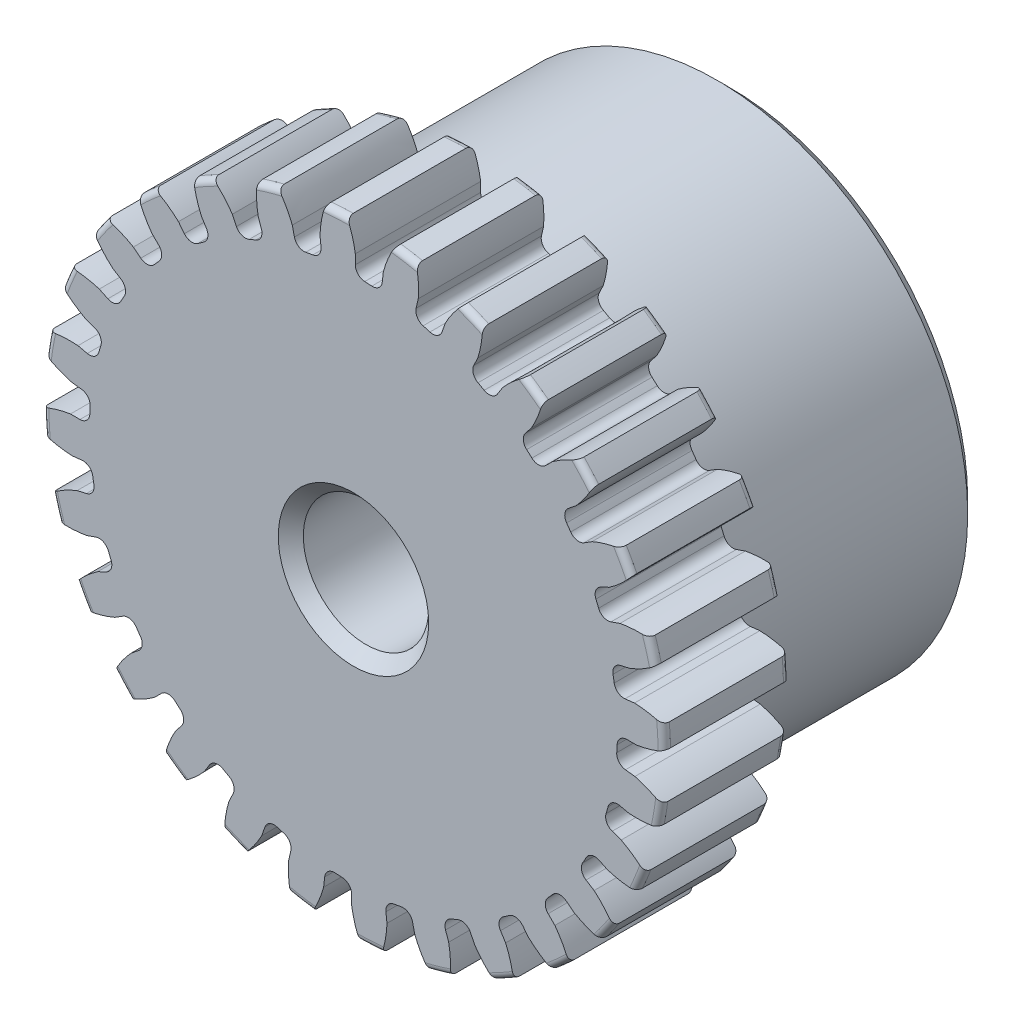
from build123d import *

# Parameters (mm, degrees)
SKETCH1_R                = 7.874
BOSS_EXTRUDE1_DEPTH      = 3.175
SKETCH2_W                = 6.35
SKETCH2_H                = 6.35
FILLET2_R                = 0.15748
CUT_EXTRUDE1_DEPTH       = 10.525
FILLET1_R                = 0.249222006
CIRPATTERN1_COUNT        = 28
FILLET1_OF_CIRPATTERN1_R = 0.249222006
SKETCH5_R                = 1.5875
CUT_EXTRUDE2_DEPTH       = 10.525
CHAMFER1_SIZE            = 0.3175


with BuildPart() as part:
    # Sketch1 → Boss-Extrude1 (new body)
    with BuildSketch(Plane.XY):
        Circle(SKETCH1_R)
    extrude(amount=-BOSS_EXTRUDE1_DEPTH)

    # Sketch2 → Revolve1 (revolve)
    with BuildSketch(Plane(origin=(0, 0, 0), x_dir=(0, 0, -1), z_dir=(1, 0, 0))):
        with Locations((6.35, 3.175)):
            Rectangle(SKETCH2_W, SKETCH2_H)
    revolve(axis=Axis((0, 0, -3.175), (0, 0, -1)))

    # Fillet2
    fillet2_edges = [part.edges().sort_by_distance(p)[0] for p in [
        (-7.874, 0, 0),
        (-7.874, 0, -3.175),
        (0, -6.35, -3.175),
    ]]
    fillet(fillet2_edges, radius=FILLET2_R)

    # Sketch4 → Cut-Extrude1 (cut, through all)
    with BuildSketch(Plane.XY):
        with BuildLine():
            Line((0.046407635, 7.16811172), (0.046407635, 6.68389425))
            ThreePointArc((0.046407635, 6.68389425), (0.374778849, 6.673540052), (0.702244628, 6.647063148))
            Line((0.702244628, 6.647063148), (0.75645991, 7.128235946))
            add(Edge.make_bspline(
                [(1.714771634, 8.558246366), (0.980352344, 7.965902347), (0.75645991, 7.128235946)],
                knots=[0, 0, 0, 1, 1, 1], degree=2))
            ThreePointArc((1.714771634, 8.558246366), (0.489403403, 8.714614559), (-0.745767657, 8.696427612))
            add(Edge.make_bspline(
                [(-0.745767657, 8.696427612), (-0.082287906, 8.025579083), (0.046407635, 7.16811172)],
                knots=[0, 0, 0, 1, 1, 1], degree=2))
        make_face()
    cut_extrude1 = extrude(amount=-CUT_EXTRUDE1_DEPTH, mode=Mode.SUBTRACT)

    # Fillet1
    fillet1_edges = [part.edges().sort_by_distance(p)[0] for p in [
        (0.702244628, 6.647063148, -1.5875),
        (0.046407635, 6.68389425, -1.5875),
    ]]
    fillet(fillet1_edges, radius=FILLET1_R)

    # CirPattern1: Cut-Extrude1 ×28 about axis
    cirpattern1_axis = Axis((0, 0, -3.175), (0, 0, 1))
    for i in range(1, CIRPATTERN1_COUNT):
        add(cut_extrude1.rotate(cirpattern1_axis, i * 360 / CIRPATTERN1_COUNT), mode=Mode.SUBTRACT)

    # Fillet1 of CirPattern1
    fillet1_of_cirpattern1_edges = [part.edges().sort_by_distance(p)[0] for p in [
        (-0.794472811, 6.636671528, -1.5875),
        (-1.442062292, 6.526641737, -1.5875),
        (-2.251352065, 6.293489485, -1.5875),
        (-2.858221195, 6.042116154, -1.5875),
        (-3.595339127, 5.6347256, -1.5875),
        (-4.131056951, 5.254613638, -1.5875),
        (-4.759040871, 4.693413044, -1.5875),
        (-5.196744263, 4.203622852, -1.5875),
        (-5.684104435, 3.516753161, -1.5875),
        (-6.001845118, 2.941844864, -1.5875),
        (-6.324143267, 2.163748589, -1.5875),
        (-6.505988396, 1.53255049, -1.5875),
        (-6.647063148, 0.702244628, -1.5875),
        (-6.68389425, 0.046407635, -1.5875),
        (-6.636671528, -0.794472811, -1.5875),
        (-6.526641737, -1.442062292, -1.5875),
        (-6.293489485, -2.251352065, -1.5875),
        (-6.042116154, -2.858221195, -1.5875),
        (-5.6347256, -3.595339127, -1.5875),
        (-5.254613638, -4.131056951, -1.5875),
        (-4.693413044, -4.759040871, -1.5875),
        (-4.203622852, -5.196744263, -1.5875),
        (-3.516753161, -5.684104435, -1.5875),
        (-2.941844864, -6.001845118, -1.5875),
        (-2.163748589, -6.324143267, -1.5875),
        (-1.53255049, -6.505988396, -1.5875),
        (-0.702244628, -6.647063148, -1.5875),
        (-0.046407635, -6.68389425, -1.5875),
        (0.794472811, -6.636671528, -1.5875),
        (1.442062292, -6.526641737, -1.5875),
        (2.251352065, -6.293489485, -1.5875),
        (2.858221195, -6.042116154, -1.5875),
        (3.595339127, -5.6347256, -1.5875),
        (4.131056951, -5.254613638, -1.5875),
        (4.759040871, -4.693413044, -1.5875),
        (5.196744263, -4.203622852, -1.5875),
        (5.684104435, -3.516753161, -1.5875),
        (6.001845118, -2.941844864, -1.5875),
        (6.324143267, -2.163748589, -1.5875),
        (6.505988396, -1.53255049, -1.5875),
        (6.647063148, -0.702244628, -1.5875),
        (6.68389425, -0.046407635, -1.5875),
        (6.636671528, 0.794472811, -1.5875),
        (6.526641737, 1.442062292, -1.5875),
        (6.293489485, 2.251352065, -1.5875),
        (6.042116154, 2.858221195, -1.5875),
        (5.6347256, 3.595339127, -1.5875),
        (5.254613638, 4.131056951, -1.5875),
        (4.693413044, 4.759040871, -1.5875),
        (4.203622852, 5.196744263, -1.5875),
        (3.516753161, 5.684104435, -1.5875),
        (2.941844864, 6.001845118, -1.5875),
        (2.163748589, 6.324143267, -1.5875),
        (1.53255049, 6.505988396, -1.5875),
    ]]
    fillet(fillet1_of_cirpattern1_edges, radius=FILLET1_OF_CIRPATTERN1_R)

    # Sketch5 → Cut-Extrude2 (cut, through all)
    with BuildSketch(Plane.XY):
        Circle(SKETCH5_R)
    extrude(amount=-CUT_EXTRUDE2_DEPTH, mode=Mode.SUBTRACT)

    # Chamfer1
    chamfer1_edges = [part.edges().sort_by_distance(p)[0] for p in [
        (-1.5875, 0, -9.525),
        (-1.5875, 0, 0),
        (0, -6.35, -9.525),
    ]]
    chamfer(chamfer1_edges, length=CHAMFER1_SIZE)


solid = part.part
